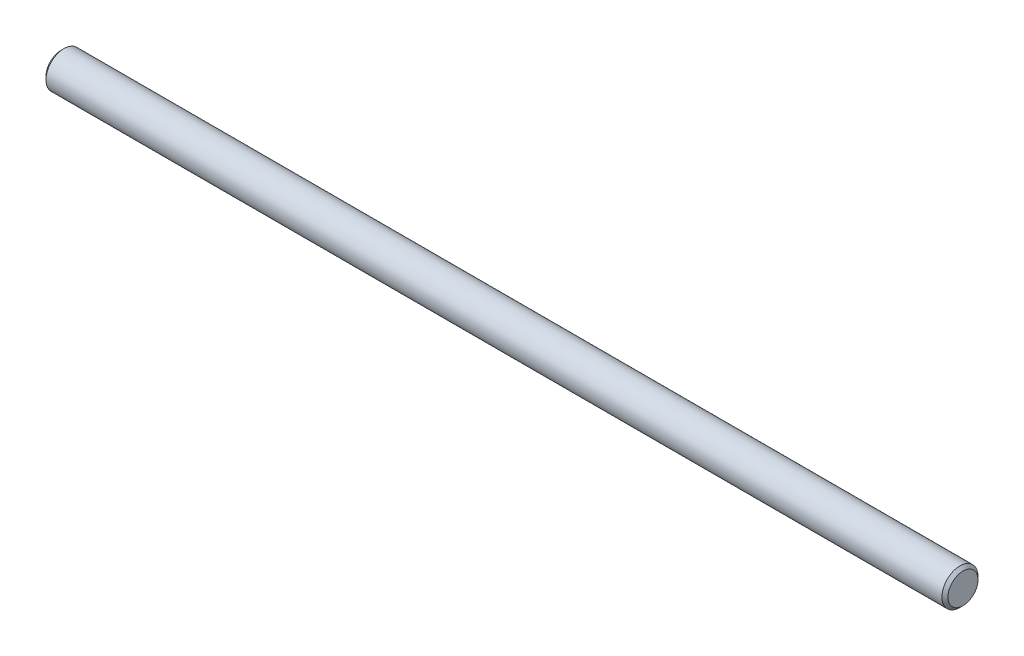
from build123d import *

# Parameters (mm, degrees)
SKETCH1_R           = 6
BOSS_EXTRUDE1_DEPTH = 300
CHAMFER1_SIZE       = 1


with BuildPart() as part:
    # Sketch1 → Boss-Extrude1 (new body)
    with BuildSketch(Plane(origin=(0, 0, 0), x_dir=(0, 0, -1), z_dir=(1, 0, 0))):
        Circle(SKETCH1_R)
    extrude(amount=BOSS_EXTRUDE1_DEPTH)

    # Chamfer1
    chamfer1_edges = [part.edges().sort_by_distance(p)[0] for p in [
        (0, 0, 6),
        (300, 0, 6),
    ]]
    chamfer(chamfer1_edges, length=CHAMFER1_SIZE)


solid = part.part
